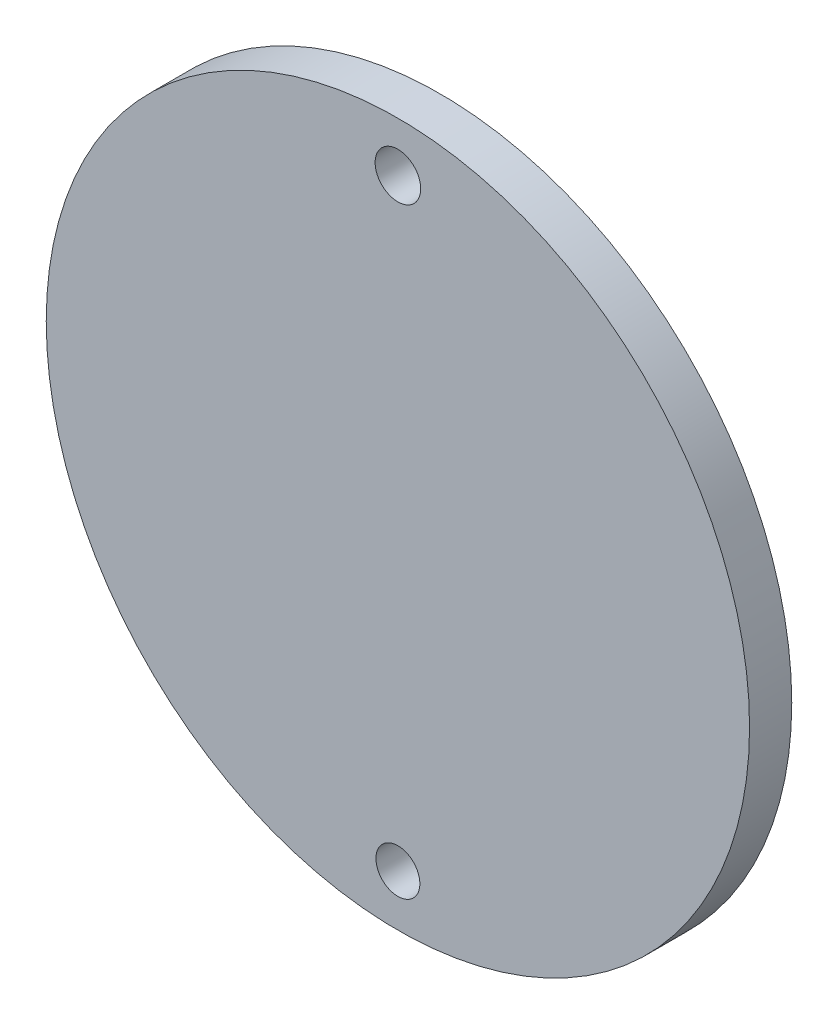
from build123d import *

# Parameters (mm, degrees)
SKETCH1_R           = 25
SKETCH1_R_2         = 1.561226439
SKETCH1_R_3         = 1.619964855
BOSS_EXTRUDE1_DEPTH = 3


with BuildPart() as part:
    # Sketch1 → Boss-Extrude1 (new body)
    with BuildSketch(Plane.XY):
        with Locations((32.470662993, 38.3744199)):
            Circle(SKETCH1_R)
        with Locations((32.470662993, 17.019406997)):
            Circle(SKETCH1_R_2, mode=Mode.SUBTRACT)
        with Locations((32.470662993, 59.834615522)):
            Circle(SKETCH1_R_3, mode=Mode.SUBTRACT)
    extrude(amount=BOSS_EXTRUDE1_DEPTH)


solid = part.part
